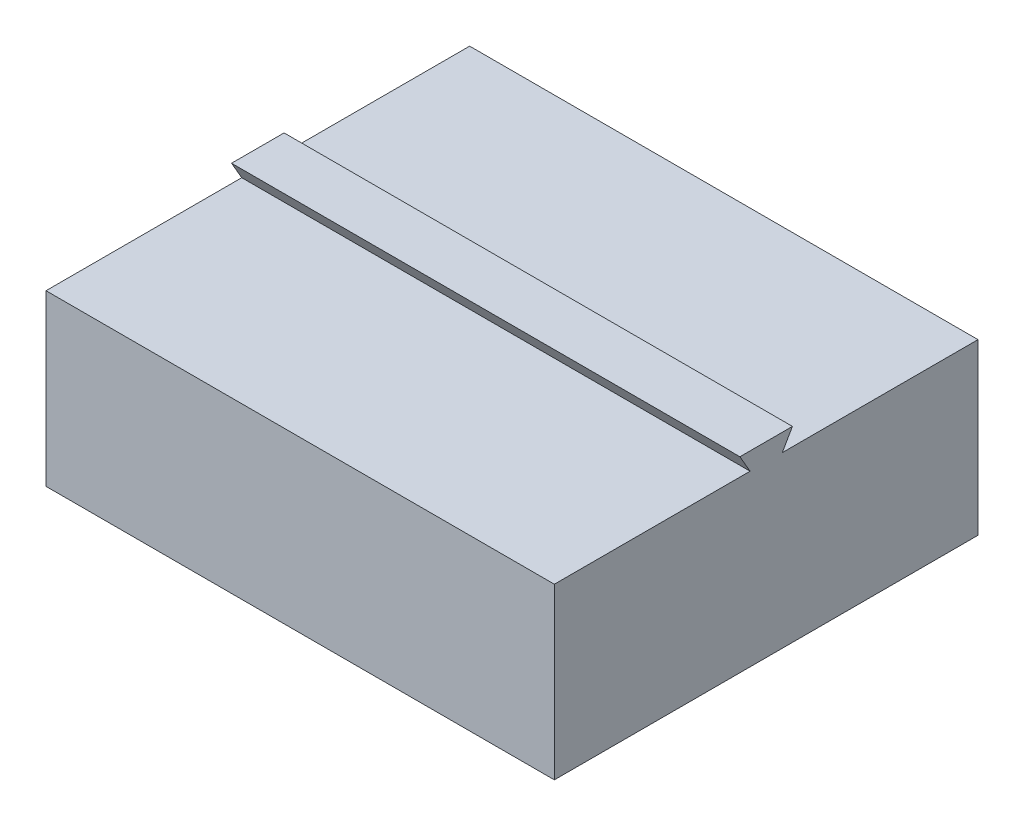
from build123d import *

# Parameters (mm, degrees)
SKETCH1_W           = 120
SKETCH1_H           = 100
BOSS_EXTRUDE1_DEPTH = 40
BOSS_EXTRUDE2_DEPTH = 120
CUT_EXTRUDE2_DEPTH  = 1


with BuildPart() as part:
    # Sketch1 → Boss-Extrude1 (new body)
    with BuildSketch(Plane(origin=(0, 0, 0), x_dir=(1, 0, 0), z_dir=(0, 1, 0))):
        Rectangle(SKETCH1_W, SKETCH1_H)
    extrude(amount=BOSS_EXTRUDE1_DEPTH)

    # Sketch2 → Boss-Extrude2 (add)
    with BuildSketch(Plane(origin=(60, 0, 0), x_dir=(0, 0, -1), z_dir=(1, 0, 0))):
        Polygon((-3.8, 40), (-6.20177712, 44.16), (6.20177712, 44.16), (3.8, 40), align=None)
    extrude(amount=-BOSS_EXTRUDE2_DEPTH)

    # Sketch5 → Cut-Extrude2 (cut)
    with BuildSketch(Plane.XZ):
        Polygon((-10.888743303, -30.135074667), (-10.888743303, 13.324383252), (-25.483702069, 13.324383252), (0, 40.546241509), (25.483702069, 13.324383252), (10.888743303, 13.324383252), (10.888743303, -30.135074667), align=None)
    extrude(amount=-CUT_EXTRUDE2_DEPTH, mode=Mode.SUBTRACT)


solid = part.part
